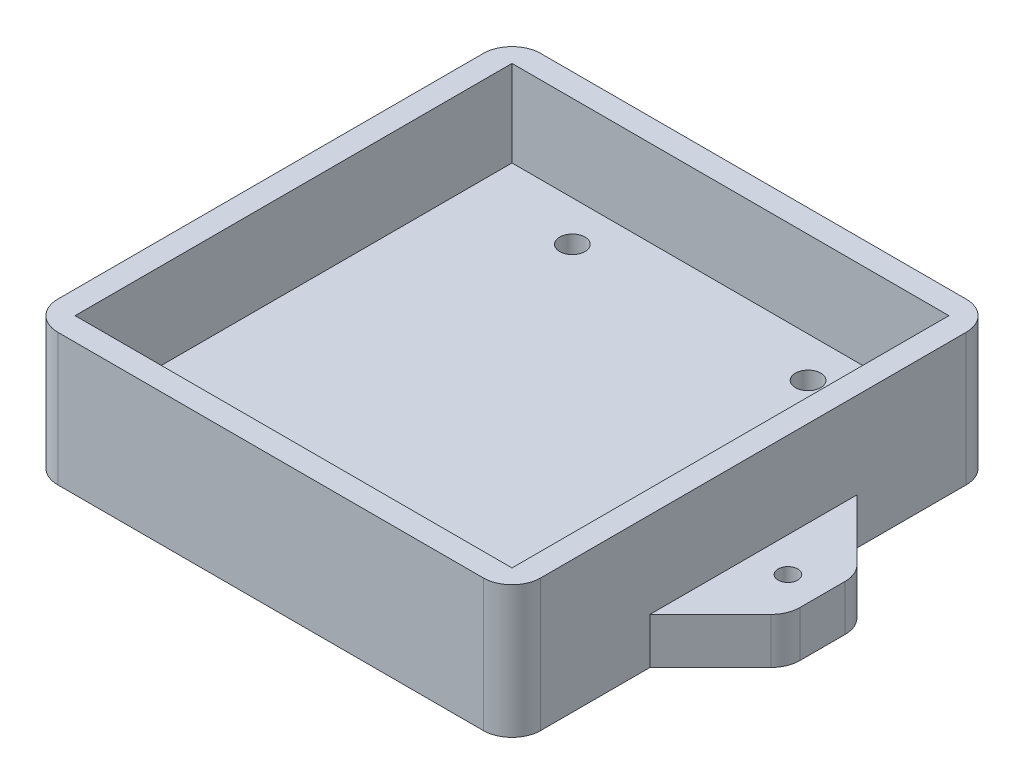
from build123d import *

# Parameters (mm, degrees)
SKETCH1_R           = 1.7
SKETCH1_R_2         = 2.2
BOSS_EXTRUDE1_DEPTH = 8
SKETCH1_3_W         = 76
SKETCH1_3_H         = 76
BOSS_EXTRUDE2_DEPTH = 15
SKETCH2_R           = 4.5
CUT_EXTRUDE1_DEPTH  = 4.5
FILLET1_R           = 5


with BuildPart() as part:
    # Sketch1 → Boss-Extrude1 (new body)
    with BuildSketch(Plane(origin=(0, 0, 0), x_dir=(1, 0, 0), z_dir=(0, 1, 0))):
        Polygon((42, 42), (-42, 42), (-42, 18), (-54, 6), (-54, -6), (-42, -18), (-42, -42), (42, -42), (42, -18), (54, -6), (54, 6), (42, 18), align=None)
        with Locations((48, 0)):
            Circle(SKETCH1_R, mode=Mode.SUBTRACT)
        with Locations((-48, 0)):
            Circle(SKETCH1_R, mode=Mode.SUBTRACT)
        with Locations((-20.5, -31)):
            Circle(SKETCH1_R_2, mode=Mode.SUBTRACT)
        with Locations((20.5, -31)):
            Circle(SKETCH1_R_2, mode=Mode.SUBTRACT)
        with Locations((-20.5, 31)):
            Circle(SKETCH1_R_2, mode=Mode.SUBTRACT)
        with Locations((20.5, 31)):
            Circle(SKETCH1_R_2, mode=Mode.SUBTRACT)
    extrude(amount=-BOSS_EXTRUDE1_DEPTH)

    # Sketch1_3 → Boss-Extrude2 (add)
    with BuildSketch(Plane(origin=(0, 0, 0), x_dir=(1, 0, 0), z_dir=(0, 1, 0))):
        Polygon((42, 42), (-42, 42), (-42, 18), (-42, 6), (-42, -6), (-42, -18), (-42, -42), (42, -42), (42, -18), (42, -6), (42, 6), (42, 18), align=None)
        Rectangle(SKETCH1_3_W, SKETCH1_3_H, mode=Mode.SUBTRACT)
    extrude(amount=BOSS_EXTRUDE2_DEPTH)

    # Sketch2 → Cut-Extrude1 (cut)
    with BuildSketch(Plane.XZ.offset(8)):
        with Locations((-20.5, 31)):
            Circle(SKETCH2_R)
        with Locations((-20.5, -31)):
            Circle(SKETCH2_R)
        with Locations((20.5, -31)):
            Circle(SKETCH2_R)
        with Locations((20.5, 31)):
            Circle(SKETCH2_R)
    extrude(amount=-CUT_EXTRUDE1_DEPTH, mode=Mode.SUBTRACT)

    # Fillet1
    fillet1_edges = [part.edges().sort_by_distance(p)[0] for p in [
        (42, 3.5, 42),
        (54, -4, 6),
        (54, -4, -6),
        (42, 3.5, -42),
        (-42, 3.5, -42),
        (-42, 3.5, 42),
        (-54, -4, 6),
        (-54, -4, -6),
    ]]
    fillet(fillet1_edges, radius=FILLET1_R)


solid = part.part
